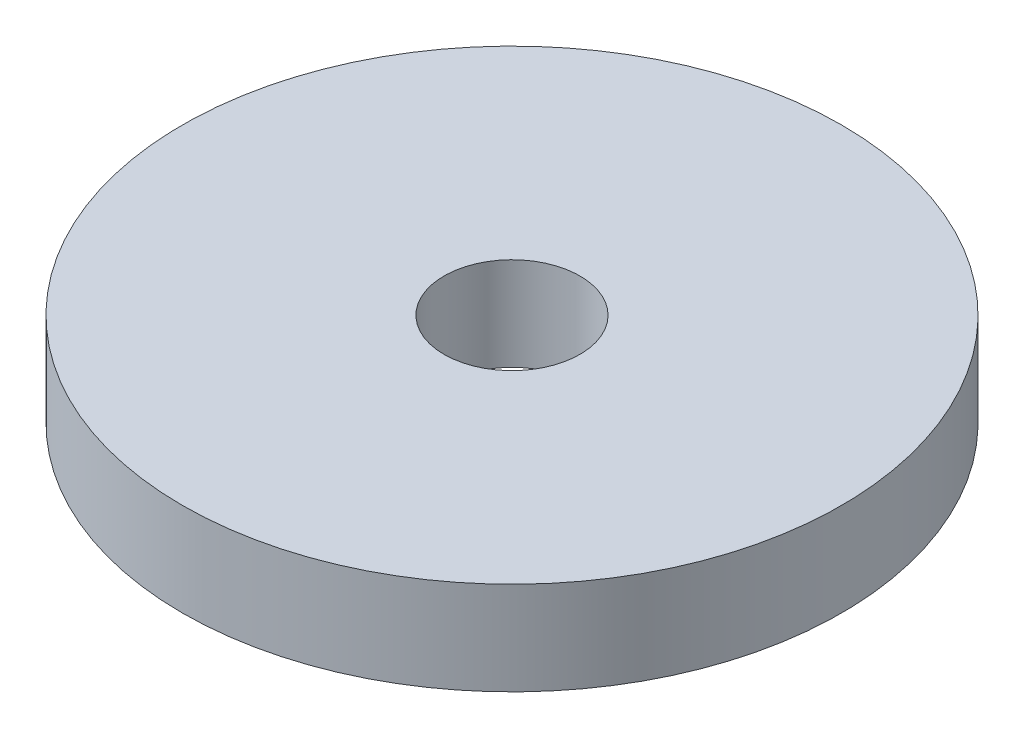
from build123d import *

# Parameters (mm, degrees)
SKETCH1_R           = 24.25
BOSS_EXTRUDE1_DEPTH = 6.86
SKETCH2_R           = 5
CUT_EXTRUDE2_DEPTH  = 6.86


with BuildPart() as part:
    # Sketch1 → Boss-Extrude1 (new body)
    with BuildSketch(Plane(origin=(0, 0, 0), x_dir=(1, 0, 0), z_dir=(0, 1, 0))):
        Circle(SKETCH1_R)
    extrude(amount=BOSS_EXTRUDE1_DEPTH)

    # Sketch2 → Cut-Extrude2 (cut)
    with BuildSketch(Plane(origin=(0, 0, 0), x_dir=(1, 0, 0), z_dir=(0, 1, 0))):
        Circle(SKETCH2_R)
    extrude(amount=CUT_EXTRUDE2_DEPTH, mode=Mode.SUBTRACT)


solid = part.part
